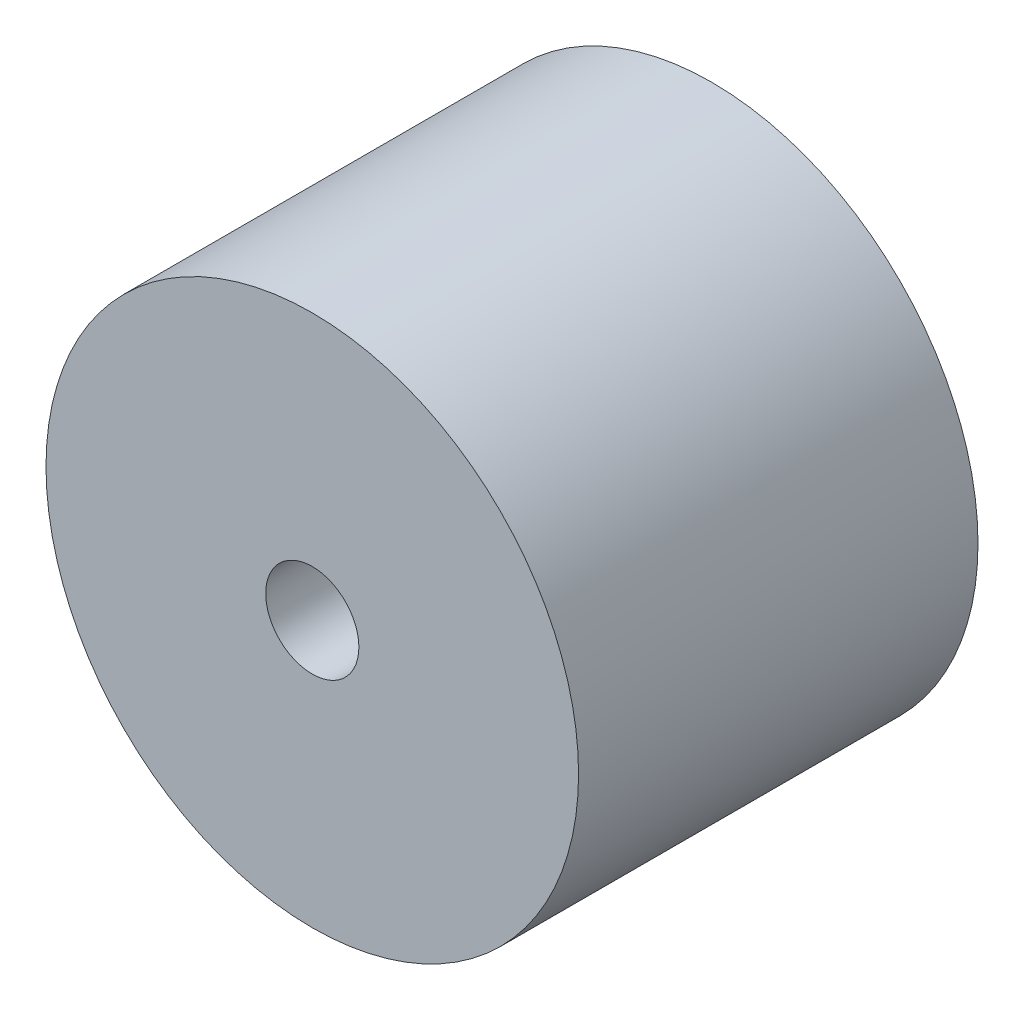
from build123d import *

# Parameters (mm, degrees)
SKETCH2_R           = 10
SKETCH2_R_2         = 1.75
BOSS_EXTRUDE1_DEPTH = 15


with BuildPart() as part:
    # Sketch2 → Boss-Extrude1 (new body)
    with BuildSketch(Plane.XY):
        Circle(SKETCH2_R)
        Circle(SKETCH2_R_2, mode=Mode.SUBTRACT)
    extrude(amount=BOSS_EXTRUDE1_DEPTH)


solid = part.part
